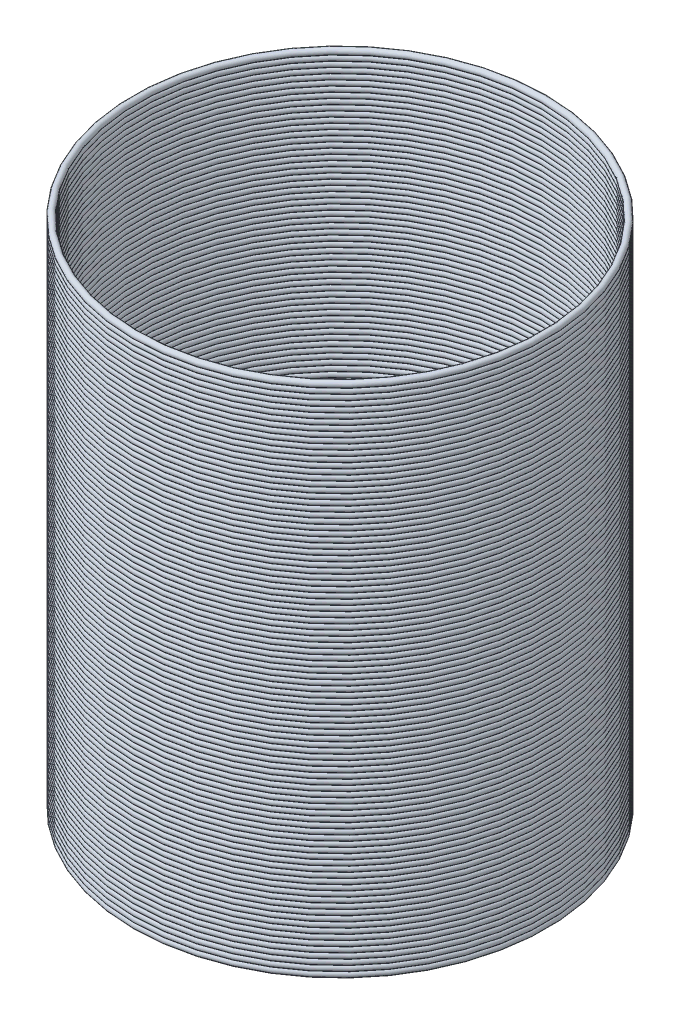
from build123d import *

# Parameters (mm, degrees)
SKETCH2_R       = 0.3
LPATTERN1_COUNT = 96
LPATTERN1_PITCH = 0.5


with BuildPart() as part:
    # Sweep1: sweep along a path in Sketch1
    with BuildLine(Plane(origin=(0, 0, 0), x_dir=(1, 0, 0), z_dir=(0, 1, 0))) as sweep1_path:
        CenterArc((0, 0), 19, 0, 360)
    # Sketch2 → Sweep1 (sweep)
    with BuildSketch(Plane.XY):
        with Locations((-19, 0)):
            Circle(SKETCH2_R)
    sweep1 = sweep(path=sweep1_path.line)

    # LPattern1: Sweep1 ×96
    with Locations(*[(0, i * LPATTERN1_PITCH, 0) for i in range(1, LPATTERN1_COUNT)]):
        add(sweep1)


solid = part.part
